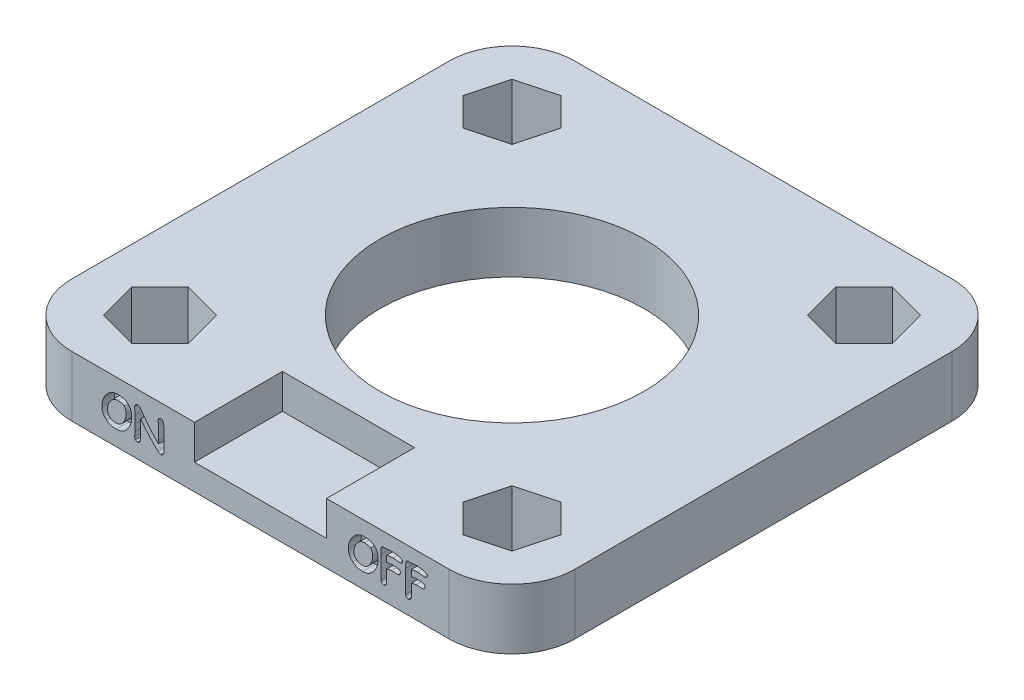
from build123d import *

# Parameters (mm, degrees)
SKICA1_W                 = 40
SKICA1_H                 = 40
SKICA1_R                 = 10.5
P_IDAT_VYSUNUT_M1_DEPTH  = 4.8
ZAOBLIT1_R               = 5
SKICA2_W                 = 10.5
SKICA2_H                 = 5.5
ODEBRAT_VYSUNUT_M1_DEPTH = 7
ODEBRAT_VYSUNUT_M2_DEPTH = 1


with BuildPart() as part:
    # Skica1 → Přidat vysunutím1 (new body)
    with BuildSketch(Plane(origin=(0, 0, 0), x_dir=(1, 0, 0), z_dir=(0, 1, 0))):
        Rectangle(SKICA1_W, SKICA1_H)
        Circle(SKICA1_R, mode=Mode.SUBTRACT)
        Polygon((-11.754634402, 11.754634402), (-10.932773553, 14.821860849), (-13.178139151, 17.067226447), (-16.245365598, 16.245365598), (-17.067226447, 13.178139151), (-14.821860849, 10.932773553), align=None, mode=Mode.SUBTRACT)
        Polygon((16.245365598, 16.245365598), (13.178139151, 17.067226447), (10.932773553, 14.821860849), (11.754634402, 11.754634402), (14.821860849, 10.932773553), (17.067226447, 13.178139151), align=None, mode=Mode.SUBTRACT)
        Polygon((16.245365598, -16.245365598), (17.067226447, -13.178139151), (14.821860849, -10.932773553), (11.754634402, -11.754634402), (10.932773553, -14.821860849), (13.178139151, -17.067226447), align=None, mode=Mode.SUBTRACT)
        Polygon((-16.245365598, -16.245365598), (-13.178139151, -17.067226447), (-10.932773553, -14.821860849), (-11.754634402, -11.754634402), (-14.821860849, -10.932773553), (-17.067226447, -13.178139151), align=None, mode=Mode.SUBTRACT)
    extrude(amount=P_IDAT_VYSUNUT_M1_DEPTH)

    # Zaoblit1
    zaoblit1_edges = [part.edges().sort_by_distance(p)[0] for p in [
        (-20, 2.4, -20),
        (20, 2.4, -20),
        (20, 2.4, 20),
        (-20, 2.4, 20),
    ]]
    fillet(zaoblit1_edges, radius=ZAOBLIT1_R)

    # Skica2 → Odebrat vysunutím1 (cut)
    with BuildSketch(Plane.XY.offset(20)):
        with Locations((0, 4.8)):
            Rectangle(SKICA2_W, SKICA2_H)
    extrude(amount=-ODEBRAT_VYSUNUT_M1_DEPTH, mode=Mode.SUBTRACT)

    # Skica4 → Odebrat vysunutím2 (cut)
    with BuildSketch(Plane.XY.offset(20)):
        with BuildLine():
            add(Edge.make_bspline(
                [(-7.675, 1.6875), (-7.675511427, 1.672680165), (-7.676669101, 1.639133729), (-7.681326512, 1.583160449), (-7.690705921, 1.516129992), (-7.697949225, 1.467739192), (-7.701851852, 1.441666667)],
                knots=[0, 0, 0, 0, 4.4483e-05, 0.000100693, 0.000168396, 0.000247488, 0.000247488, 0.000247488, 0.000247488], degree=3))
            add(Edge.make_bspline(
                [(-7.701851852, 1.441666667), (-7.704730232, 1.425795592), (-7.710210981, 1.395575329), (-7.726150475, 1.354217439), (-7.747242624, 1.319326551), (-7.773168281, 1.289940389), (-7.805193965, 1.267699725), (-7.842156121, 1.251696892), (-7.884276351, 1.242463261), (-7.913995971, 1.241334508), (-7.92962963, 1.240740741)],
                knots=[0, 0, 0, 0, 4.8308e-05, 9.1984e-05, 0.00013208, 0.000170105, 0.00020864, 0.000248033, 0.000290264, 0.000337135, 0.000337135, 0.000337135, 0.000337135], degree=3))
            add(Edge.make_bspline(
                [(-7.92962963, 1.240740741), (-7.938920109, 1.241081214), (-7.957997788, 1.241780364), (-7.986728041, 1.248240416), (-8.016262223, 1.258205907), (-8.046693038, 1.271577755), (-8.078048841, 1.289073024), (-8.110195974, 1.310312478), (-8.143340092, 1.335475378), (-8.164785779, 1.354479828), (-8.175925926, 1.364351852)],
                knots=[0, 0, 0, 0, 2.7839e-05, 5.7167e-05, 8.7912e-05, 0.000121287, 0.000156721, 0.000195499, 0.000236797, 0.000281438, 0.000281438, 0.000281438, 0.000281438], degree=3))
            add(Edge.make_bspline(
                [(-8.175925926, 1.364351852), (-8.201308744, 1.3874192), (-8.252786123, 1.434200714), (-8.329763202, 1.506939901), (-8.407365743, 1.583681364), (-8.487167676, 1.662997238), (-8.567559016, 1.746360031), (-8.648982608, 1.833282723), (-8.732566347, 1.922608612), (-8.816068769, 2.01666789), (-8.901836173, 2.113052363), (-8.988450373, 2.213317447), (-9.076331212, 2.316814446), (-9.165139145, 2.423960411), (-9.255637306, 2.534001749), (-9.346594942, 2.64806528), (-9.439421484, 2.765168862), (-9.501155437, 2.844848471), (-9.532407407, 2.885185185)],
                knots=[0, 0, 0, 0, 0.000102894, 0.000208674, 0.000317691, 0.000430304, 0.000546208, 0.000665096, 0.000787616, 0.000913184, 0.001042405, 0.001174674, 0.001310659, 0.001449721, 0.001592167, 0.001738074, 0.001887382, 0.002040461, 0.002040461, 0.002040461, 0.002040461], degree=3))
            add(Edge.make_bspline(
                [(-9.532407407, 2.885185185), (-9.533211671, 2.852932842), (-9.534739345, 2.791670556), (-9.536404499, 2.704780063), (-9.538402842, 2.627780862), (-9.53984509, 2.560651506), (-9.540602809, 2.503238161), (-9.54166635, 2.455558488), (-9.542202023, 2.417748159), (-9.542151132, 2.395833424), (-9.54212963, 2.386574074)],
                knots=[0, 0, 0, 0, 9.6787e-05, 0.000183844, 0.000260718, 0.000327862, 0.000385277, 0.000432971, 0.000470937, 0.000498714, 0.000498714, 0.000498714, 0.000498714], degree=3))
            add(Edge.make_bspline(
                [(-9.54212963, 2.386574074), (-9.542178103, 2.375616956), (-9.542280516, 2.35246714), (-9.541413081, 2.315743629), (-9.542008358, 2.275147603), (-9.540440371, 2.230561865), (-9.540459618, 2.182094232), (-9.539261113, 2.129630937), (-9.53837092, 2.073303523), (-9.537668837, 2.014345624), (-9.53597861, 1.955561133), (-9.535296212, 1.899380869), (-9.534140414, 1.847071663), (-9.533853328, 1.798610433), (-9.533331962, 1.754012331), (-9.532940471, 1.713425303), (-9.532295161, 1.676699235), (-9.532371347, 1.653549616), (-9.532407407, 1.642592593)],
                knots=[0, 0, 0, 0, 3.287e-05, 6.9447e-05, 0.000110188, 0.000154642, 0.000203256, 0.000255579, 0.000312068, 0.00037226, 0.000432461, 0.000488487, 0.00054081, 0.000589424, 0.00063387, 0.000674614, 0.000711191, 0.000744061, 0.000744061, 0.000744061, 0.000744061], degree=3))
            add(Edge.make_bspline(
                [(-9.532407407, 1.642592593), (-9.532551422, 1.623914249), (-9.532828913, 1.587924434), (-9.535894121, 1.535757937), (-9.539611953, 1.487029933), (-9.546283713, 1.441971649), (-9.554003323, 1.400346416), (-9.563614635, 1.36240846), (-9.575133233, 1.328014341), (-9.588429995, 1.297215657), (-9.603955118, 1.270280491), (-9.620375128, 1.246152691), (-9.639548216, 1.22631449), (-9.660087891, 1.209699676), (-9.682615625, 1.196984891), (-9.706937261, 1.188381823), (-9.732892375, 1.182390183), (-9.750889754, 1.181790968), (-9.760185185, 1.181481481)],
                knots=[0, 0, 0, 0, 5.6026e-05, 0.000107952, 0.000156742, 0.000202573, 0.000244521, 0.000283709, 0.000319871, 0.000353246, 0.00038414, 0.000413041, 0.000440547, 0.000466576, 0.000492073, 0.000517704, 0.000543766, 0.000571605, 0.000571605, 0.000571605, 0.000571605], degree=3))
            add(Edge.make_bspline(
                [(-9.760185185, 1.181481481), (-9.77848016, 1.182370462), (-9.813712587, 1.184082458), (-9.86386568, 1.197234545), (-9.908537754, 1.219441479), (-9.932825116, 1.241084865), (-9.944907407, 1.251851852)],
                knots=[0, 0, 0, 0, 5.4825e-05, 0.000105583, 0.000154447, 0.000202819, 0.000202819, 0.000202819, 0.000202819], degree=3))
            add(Edge.make_bspline(
                [(-9.944907407, 1.251851852), (-9.95431763, 1.262472954), (-9.972820924, 1.283357195), (-9.992537503, 1.32044514), (-10.004548777, 1.360828141), (-10.005830699, 1.388959533), (-10.006481481, 1.403240741)],
                knots=[0, 0, 0, 0, 4.2444e-05, 8.3457e-05, 0.00012492, 0.000167674, 0.000167674, 0.000167674, 0.000167674], degree=3))
            add(Edge.make_bspline(
                [(-10.006481481, 1.403240741), (-10.006408492, 1.415125665), (-10.006247274, 1.441377168), (-10.004012298, 1.484731606), (-10.001453692, 1.535988986), (-9.997221437, 1.59259256), (-9.992993684, 1.649196322), (-9.990416232, 1.700607223), (-9.988212611, 1.743962883), (-9.988040066, 1.770213972), (-9.987962963, 1.781944444)],
                knots=[0, 0, 0, 0, 3.5651e-05, 7.8747e-05, 0.00013021, 0.000189616, 0.000249022, 0.000300485, 0.000344043, 0.000379232, 0.000379232, 0.000379232, 0.000379232], degree=3))
            add(Edge.make_bspline(
                [(-9.987962963, 1.781944444), (-9.98782225, 1.799228478), (-9.987509403, 1.837655999), (-9.986661924, 1.900933966), (-9.984600036, 1.97577271), (-9.982408805, 2.058333368), (-9.980205469, 2.141048046), (-9.978158964, 2.216041497), (-9.977304677, 2.279473613), (-9.976992337, 2.317901146), (-9.976851852, 2.335185185)],
                knots=[0, 0, 0, 0, 5.1854e-05, 0.000115287, 0.000189847, 0.000276452, 0.000363057, 0.00043808, 0.000501512, 0.000553366, 0.000553366, 0.000553366, 0.000553366], degree=3))
            add(Edge.make_bspline(
                [(-9.976851852, 2.335185185), (-9.97678822, 2.353704155), (-9.976646633, 2.394910961), (-9.977970855, 2.462806695), (-9.978652907, 2.543212466), (-9.980034143, 2.63194495), (-9.981752747, 2.720827498), (-9.981605453, 2.801393435), (-9.983101732, 2.869440664), (-9.982942108, 2.910647627), (-9.98287037, 2.929166667)],
                knots=[0, 0, 0, 0, 5.5556e-05, 0.000123617, 0.000203715, 0.000296781, 0.000389847, 0.000470404, 0.000538466, 0.000594021, 0.000594021, 0.000594021, 0.000594021], degree=3))
            add(Edge.make_bspline(
                [(-9.98287037, 2.929166667), (-9.983158143, 2.946759248), (-9.983796888, 2.985808011), (-9.985355078, 3.050045791), (-9.990133751, 3.125618751), (-9.994868779, 3.208952511), (-9.999876142, 3.292264377), (-10.003856848, 3.368025092), (-10.005580831, 3.432246198), (-10.006201743, 3.471295889), (-10.006481481, 3.488888889)],
                knots=[0, 0, 0, 0, 5.2786e-05, 0.000117164, 0.000192742, 0.000279928, 0.000367576, 0.00044313, 0.000507509, 0.000560294, 0.000560294, 0.000560294, 0.000560294], degree=3))
            add(Edge.make_bspline(
                [(-10.006481481, 3.488888889), (-10.005498041, 3.504293031), (-10.003543578, 3.534906799), (-9.987767889, 3.579006901), (-9.962498502, 3.620217196), (-9.927903294, 3.657124199), (-9.887891573, 3.689377385), (-9.842904366, 3.712304065), (-9.795369388, 3.727098946), (-9.762453869, 3.728780525), (-9.745833333, 3.72962963)],
                knots=[0, 0, 0, 0, 4.6115e-05, 9.1648e-05, 0.000138812, 0.000190259, 0.00024268, 0.000292167, 0.000340946, 0.000390699, 0.000390699, 0.000390699, 0.000390699], degree=3))
            add(Edge.make_bspline(
                [(-9.745833333, 3.72962963), (-9.736044085, 3.728939831), (-9.715899661, 3.727520354), (-9.685625695, 3.717509608), (-9.655061251, 3.701465563), (-9.623732637, 3.679242201), (-9.591958306, 3.650671327), (-9.558993507, 3.616170295), (-9.525299697, 3.575456888), (-9.50381988, 3.54536064), (-9.492592593, 3.52962963)],
                knots=[0, 0, 0, 0, 2.9346e-05, 6.0389e-05, 9.4761e-05, 0.00013265, 0.000175288, 0.000222766, 0.0002757, 0.000333666, 0.000333666, 0.000333666, 0.000333666], degree=3))
            add(Edge.make_bspline(
                [(-9.492592593, 3.52962963), (-9.434624361, 3.446806863), (-9.320656625, 3.28397417), (-9.146260709, 3.048194745), (-8.972750905, 2.823946105), (-8.799617494, 2.611320211), (-8.627126941, 2.410381302), (-8.455159881, 2.221255869), (-8.284216532, 2.043398787), (-8.167511555, 1.931712837), (-8.110185185, 1.876851852)],
                knots=[0, 0, 0, 0, 0.00030327, 0.000596241, 0.000879702, 0.001153812, 0.001418749, 0.001674053, 0.001920595, 0.002158616, 0.002158616, 0.002158616, 0.002158616], degree=3))
            add(Edge.make_bspline(
                [(-8.110185185, 1.876851852), (-8.109988216, 1.881635158), (-8.109530875, 1.892741484), (-8.109924711, 1.911578007), (-8.109000506, 1.93471804), (-8.109479001, 1.962040033), (-8.108571636, 1.993669972), (-8.108867579, 2.029630179), (-8.108775419, 2.069907246), (-8.108789113, 2.098148093), (-8.108796296, 2.112962963)],
                knots=[0, 0, 0, 0, 1.4359e-05, 3.3341e-05, 5.6494e-05, 8.3808e-05, 0.000115293, 0.000151404, 0.000191682, 0.000236127, 0.000236127, 0.000236127, 0.000236127], degree=3))
            add(Edge.make_bspline(
                [(-8.108796296, 2.112962963), (-8.108813437, 2.144290077), (-8.108846958, 2.205555418), (-8.108607371, 2.295525618), (-8.109459456, 2.381480515), (-8.109078935, 2.463581233), (-8.109758042, 2.541820882), (-8.110144507, 2.616204006), (-8.110695584, 2.686727832), (-8.110900117, 2.753244749), (-8.112222161, 2.815891192), (-8.112306081, 2.874695585), (-8.11342801, 2.929629834), (-8.114305612, 2.98055631), (-8.115235434, 3.027624511), (-8.116201545, 3.070832899), (-8.116932334, 3.110196304), (-8.118009777, 3.13503232), (-8.118518519, 3.146759259)],
                knots=[0, 0, 0, 0, 9.3981e-05, 0.000183796, 0.000269909, 0.000351853, 0.000430095, 0.000504634, 0.000575006, 0.000641674, 0.000704181, 0.000762979, 0.000818079, 0.000869014, 0.000915782, 0.00095931, 0.000998673, 0.001033886, 0.001033886, 0.001033886, 0.001033886], degree=3))
            add(Edge.make_bspline(
                [(-8.118518519, 3.146759259), (-8.118965229, 3.155865011), (-8.120018046, 3.177325674), (-8.122304892, 3.214379381), (-8.126210891, 3.261113401), (-8.129019082, 3.295524283), (-8.130555556, 3.314351852)],
                knots=[0, 0, 0, 0, 2.735e-05, 6.4459e-05, 0.000111365, 0.000168036, 0.000168036, 0.000168036, 0.000168036], degree=3))
            add(Edge.make_bspline(
                [(-8.130555556, 3.314351852), (-8.132036264, 3.331475143), (-8.134835699, 3.363848536), (-8.137392637, 3.409555281), (-8.139600915, 3.449515973), (-8.139747196, 3.474225888), (-8.139814815, 3.485648148)],
                knots=[0, 0, 0, 0, 5.1558e-05, 9.7475e-05, 0.000137333, 0.000171595, 0.000171595, 0.000171595, 0.000171595], degree=3))
            add(Edge.make_bspline(
                [(-8.139814815, 3.485648148), (-8.139107689, 3.502521065), (-8.13777595, 3.534298058), (-8.127874444, 3.578820932), (-8.1100512, 3.61672737), (-8.084303566, 3.64742075), (-8.051867275, 3.671961514), (-8.011836365, 3.688237651), (-7.965341287, 3.698597999), (-7.932007884, 3.699514531), (-7.914351852, 3.7)],
                knots=[0, 0, 0, 0, 5.0599e-05, 9.5293e-05, 0.000135878, 0.000175001, 0.000214353, 0.000256663, 0.000303614, 0.000356491, 0.000356491, 0.000356491, 0.000356491], degree=3))
            add(Edge.make_bspline(
                [(-7.914351852, 3.7), (-7.904109101, 3.69931314), (-7.883858826, 3.697955195), (-7.854457832, 3.688987364), (-7.827416078, 3.673108337), (-7.802955346, 3.650814869), (-7.779918411, 3.623008698), (-7.759259386, 3.588946763), (-7.74092618, 3.548735918), (-7.724361835, 3.502711815), (-7.709643732, 3.450562123), (-7.696798423, 3.392448054), (-7.68631421, 3.328123521), (-7.67762089, 3.25784816), (-7.670773441, 3.181259005), (-7.665663258, 3.098671741), (-7.66301741, 3.009894256), (-7.662676462, 2.948766993), (-7.6625, 2.91712963)],
                knots=[0, 0, 0, 0, 3.0727e-05, 6.0748e-05, 9.1241e-05, 0.000124036, 0.000159542, 0.000199244, 0.000243155, 0.000291924, 0.000345851, 0.000405607, 0.000470378, 0.000541296, 0.000618, 0.000701026, 0.000789496, 0.000884408, 0.000884408, 0.000884408, 0.000884408], degree=3))
            add(Edge.make_bspline(
                [(-7.6625, 2.91712963), (-7.662502308, 2.91466052), (-7.662509087, 2.907407512), (-7.662405402, 2.893207072), (-7.663094897, 2.872378661), (-7.663451442, 2.844907821), (-7.663932278, 2.810803008), (-7.664405643, 2.770062341), (-7.664738916, 2.722836409), (-7.665392791, 2.689197005), (-7.665740741, 2.671296296)],
                knots=[0, 0, 0, 0, 7.407e-06, 2.1759e-05, 4.2598e-05, 6.9916e-05, 0.000104179, 0.000144922, 0.000192147, 0.000245858, 0.000245858, 0.000245858, 0.000245858], degree=3))
            add(Edge.make_bspline(
                [(-7.665740741, 2.671296296), (-7.665990759, 2.639196801), (-7.666479993, 2.576384661), (-7.668179686, 2.484571473), (-7.668934688, 2.397375947), (-7.669833129, 2.3149684), (-7.670997312, 2.237194309), (-7.671067907, 2.16403942), (-7.672368996, 2.095527788), (-7.672630296, 2.031635286), (-7.673133211, 1.972376455), (-7.673605286, 1.917901118), (-7.673990872, 1.868055), (-7.674718292, 1.822995629), (-7.674316364, 1.782405037), (-7.675147453, 1.746606865), (-7.674971466, 1.715431917), (-7.674991014, 1.696296239), (-7.675, 1.6875)],
                knots=[0, 0, 0, 0, 9.6301e-05, 0.000188441, 0.000275483, 0.000357895, 0.000435679, 0.000508828, 0.000577353, 0.000641244, 0.000700505, 0.000755136, 0.000804676, 0.000850048, 0.000890326, 0.00092644, 0.000957459, 0.000983848, 0.000983848, 0.000983848, 0.000983848], degree=3))
        make_face()
        with BuildLine():
            add(Edge.make_bspline(
                [(-11.475925926, 1.211111111), (-11.513924551, 1.211878388), (-11.588590406, 1.213386058), (-11.698518349, 1.22627778), (-11.803949591, 1.246954828), (-11.905396947, 1.275662725), (-12.002111211, 1.313342182), (-12.094929428, 1.358850221), (-12.183252906, 1.413061288), (-12.238160298, 1.455214818), (-12.265740741, 1.476388889)],
                knots=[0, 0, 0, 0, 0.000113965, 0.000223937, 0.000331529, 0.000436012, 0.000539784, 0.000642479, 0.000745782, 0.000850043, 0.000850043, 0.000850043, 0.000850043], degree=3))
            add(Edge.make_bspline(
                [(-12.265740741, 1.476388889), (-12.293439014, 1.500358502), (-12.347845978, 1.547441362), (-12.419098636, 1.626781287), (-12.479160157, 1.711558542), (-12.528740928, 1.801363321), (-12.566795992, 1.89660731), (-12.594281845, 1.996880477), (-12.61071178, 2.102544857), (-12.612816927, 2.174787449), (-12.613888889, 2.211574074)],
                knots=[0, 0, 0, 0, 0.000109808, 0.000215693, 0.000318971, 0.000420912, 0.000522701, 0.000625918, 0.000732252, 0.000842578, 0.000842578, 0.000842578, 0.000842578], degree=3))
            add(Edge.make_bspline(
                [(-12.613888889, 2.211574074), (-12.612971602, 2.255297134), (-12.61115042, 2.342104908), (-12.594665415, 2.470747926), (-12.569053938, 2.596584431), (-12.532191464, 2.719397676), (-12.484708639, 2.839159434), (-12.427069417, 2.955994396), (-12.35950786, 3.07024689), (-12.306792735, 3.142239527), (-12.280092593, 3.178703704)],
                knots=[0, 0, 0, 0, 0.000131117, 0.000260321, 0.000388434, 0.000516011, 0.000644452, 0.000774478, 0.000906516, 0.001042032, 0.001042032, 0.001042032, 0.001042032], degree=3))
            add(Edge.make_bspline(
                [(-12.280092593, 3.178703704), (-12.264410075, 3.198786289), (-12.233516561, 3.238347644), (-12.184112043, 3.293902585), (-12.133648966, 3.346026406), (-12.081434838, 3.394141669), (-12.027523057, 3.438189993), (-11.972328611, 3.478737274), (-11.915327301, 3.515195551), (-11.857053538, 3.548283709), (-11.797065453, 3.576878562), (-11.735860089, 3.602250036), (-11.672688987, 3.622701493), (-11.608399939, 3.640606313), (-11.542494622, 3.654051999), (-11.475026704, 3.662978555), (-11.406144614, 3.669488089), (-11.359583564, 3.670074665), (-11.336111111, 3.67037037)],
                knots=[0, 0, 0, 0, 7.6424e-05, 0.00015055, 0.000222904, 0.000294003, 0.000363418, 0.000431664, 0.000499342, 0.000566299, 0.000632561, 0.000698588, 0.000764909, 0.000831622, 0.00089872, 0.000966485, 0.001035728, 0.001106123, 0.001106123, 0.001106123, 0.001106123], degree=3))
            add(Edge.make_bspline(
                [(-11.336111111, 3.67037037), (-11.291943277, 3.669794678), (-11.206209347, 3.668677206), (-11.082020358, 3.656217695), (-10.966162804, 3.637217959), (-10.858883204, 3.610054371), (-10.760114932, 3.575036708), (-10.670201899, 3.531701705), (-10.588256903, 3.481204395), (-10.515284525, 3.42209487), (-10.450755036, 3.355252361), (-10.394602907, 3.280630938), (-10.348038433, 3.197549585), (-10.309275319, 3.107148036), (-10.279885672, 3.008752494), (-10.25885365, 2.902734973), (-10.245589224, 2.788915656), (-10.244222685, 2.710377501), (-10.243518519, 2.669907407)],
                knots=[0, 0, 0, 0, 0.000132459, 0.000257116, 0.000374022, 0.0004844, 0.000588664, 0.000687848, 0.000783297, 0.000876786, 0.00096879, 0.001061382, 0.001156132, 0.001253821, 0.001355901, 0.001463584, 0.001577748, 0.001699116, 0.001699116, 0.001699116, 0.001699116], degree=3))
            add(Edge.make_bspline(
                [(-10.243518519, 2.669907407), (-10.244352765, 2.626193859), (-10.246005229, 2.539606701), (-10.260903308, 2.411288165), (-10.284772295, 2.28601213), (-10.31885002, 2.163959459), (-10.36185509, 2.044936317), (-10.415131147, 1.929313931), (-10.477313805, 1.816285261), (-10.526245557, 1.744834754), (-10.550925926, 1.708796296)],
                knots=[0, 0, 0, 0, 0.0001311, 0.000259682, 0.000386979, 0.000513341, 0.000639438, 0.000766223, 0.000894919, 0.00102589, 0.00102589, 0.00102589, 0.00102589], degree=3))
            add(Edge.make_bspline(
                [(-10.550925926, 1.708796296), (-10.565649186, 1.688542987), (-10.594807189, 1.648433253), (-10.642181498, 1.59247918), (-10.690368163, 1.539481513), (-10.740966842, 1.491166506), (-10.79268027, 1.44589285), (-10.846630931, 1.405313717), (-10.901694131, 1.367931773), (-10.95891015, 1.335066247), (-11.017710912, 1.305968515), (-11.078018129, 1.280210784), (-11.140312165, 1.259063361), (-11.20410534, 1.241344467), (-11.269727632, 1.227991526), (-11.336967352, 1.21834675), (-11.405897938, 1.212034058), (-11.452455322, 1.211420446), (-11.475925926, 1.211111111)],
                knots=[0, 0, 0, 0, 7.5093e-05, 0.000148714, 0.000219813, 0.000289881, 0.000358477, 0.000425885, 0.00049227, 0.00055802, 0.000623653, 0.000689003, 0.000754594, 0.000820861, 0.000887505, 0.000955335, 0.001024578, 0.001094973, 0.001094973, 0.001094973, 0.001094973], degree=3))
        make_face()
        with BuildLine():
            add(Edge.make_bspline(
                [(-11.336111111, 3.255555556), (-11.364902017, 3.254704064), (-11.421724115, 3.25302355), (-11.505023923, 3.235757178), (-11.585508715, 3.209548111), (-11.662519813, 3.171587771), (-11.736370673, 3.123245603), (-11.807060112, 3.064436951), (-11.874363135, 2.99469228), (-11.914845899, 2.942233801), (-11.935648148, 2.915277778)],
                knots=[0, 0, 0, 0, 8.6262e-05, 0.000170247, 0.000254135, 0.000339648, 0.000426967, 0.000518371, 0.000614957, 0.000717049, 0.000717049, 0.000717049, 0.000717049], degree=3))
            add(Edge.make_bspline(
                [(-11.935648148, 2.915277778), (-11.954274394, 2.88869707), (-11.99119738, 2.836005877), (-12.038846865, 2.752824455), (-12.079243094, 2.667527112), (-12.112325969, 2.580080784), (-12.137932771, 2.490416051), (-12.155704589, 2.398540239), (-12.167404983, 2.304621639), (-12.168760515, 2.241238854), (-12.169444444, 2.209259259)],
                knots=[0, 0, 0, 0, 9.7332e-05, 0.000192943, 0.00028717, 0.000380208, 0.000473117, 0.000566545, 0.000660721, 0.000756626, 0.000756626, 0.000756626, 0.000756626], degree=3))
            add(Edge.make_bspline(
                [(-12.169444444, 2.209259259), (-12.168801209, 2.187930374), (-12.167536481, 2.145993592), (-12.158183712, 2.084619134), (-12.14247421, 2.02631615), (-12.120007889, 1.971156115), (-12.091139628, 1.919174874), (-12.056164434, 1.870151279), (-12.014655551, 1.824482189), (-11.983165348, 1.797217367), (-11.96712963, 1.783333333)],
                knots=[0, 0, 0, 0, 6.3971e-05, 0.00012578, 0.000185753, 0.000244729, 0.000303995, 0.000363734, 0.000425022, 0.000488615, 0.000488615, 0.000488615, 0.000488615], degree=3))
            add(Edge.make_bspline(
                [(-11.96712963, 1.783333333), (-11.950536892, 1.770662495), (-11.91748584, 1.745423468), (-11.863657419, 1.713264999), (-11.806561864, 1.686656485), (-11.746597747, 1.664115195), (-11.68328242, 1.647185942), (-11.617071378, 1.634672271), (-11.547554424, 1.627070689), (-11.500173755, 1.626313453), (-11.475925926, 1.625925926)],
                knots=[0, 0, 0, 0, 6.2596e-05, 0.000124685, 0.000187643, 0.000251365, 0.000316617, 0.00038399, 0.000453368, 0.00052609, 0.00052609, 0.00052609, 0.00052609], degree=3))
            add(Edge.make_bspline(
                [(-11.475925926, 1.625925926), (-11.44759706, 1.626781161), (-11.391691028, 1.628468938), (-11.310049618, 1.645620862), (-11.231763737, 1.671755074), (-11.157727945, 1.710130031), (-11.086811029, 1.758056011), (-11.019795786, 1.817117535), (-10.956629111, 1.886856818), (-10.919233004, 1.939255038), (-10.9, 1.966203704)],
                knots=[0, 0, 0, 0, 8.4875e-05, 0.000167498, 0.000249192, 0.000331805, 0.00041681, 0.000505395, 0.000599133, 0.000698393, 0.000698393, 0.000698393, 0.000698393], degree=3))
            add(Edge.make_bspline(
                [(-10.9, 1.966203704), (-10.883078673, 1.992347779), (-10.849458932, 2.044291519), (-10.806436696, 2.126284588), (-10.769703294, 2.21075275), (-10.739566138, 2.297861255), (-10.716204817, 2.387634709), (-10.700436119, 2.480128647), (-10.689600558, 2.575206643), (-10.688513118, 2.639629532), (-10.687962963, 2.672222222)],
                knots=[0, 0, 0, 0, 9.3388e-05, 0.000185545, 0.0002774, 0.000369492, 0.000461794, 0.000555338, 0.00065079, 0.000748529, 0.000748529, 0.000748529, 0.000748529], degree=3))
            add(Edge.make_bspline(
                [(-10.687962963, 2.672222222), (-10.688367495, 2.698781978), (-10.689145146, 2.749839002), (-10.696148345, 2.82334226), (-10.707464285, 2.890582184), (-10.723446891, 2.951617201), (-10.744439327, 3.006181566), (-10.769198783, 3.054927664), (-10.799416894, 3.097388386), (-10.823701782, 3.120860745), (-10.835648148, 3.132407407)],
                knots=[0, 0, 0, 0, 7.9663e-05, 0.00015314, 0.00022126, 0.000284036, 0.000342071, 0.000396322, 0.00044772, 0.000497483, 0.000497483, 0.000497483, 0.000497483], degree=3))
            add(Edge.make_bspline(
                [(-10.835648148, 3.132407407), (-10.848360505, 3.14234639), (-10.874697186, 3.162937365), (-10.920936411, 3.187669578), (-10.973578727, 3.208907132), (-11.032973463, 3.226321078), (-11.09911277, 3.23968506), (-11.172042181, 3.248398265), (-11.251739735, 3.254788404), (-11.307238543, 3.25529303), (-11.336111111, 3.255555556)],
                knots=[0, 0, 0, 0, 4.8335e-05, 0.000100137, 0.00015662, 0.000218436, 0.000285534, 0.000358806, 0.000438663, 0.000525257, 0.000525257, 0.000525257, 0.000525257], degree=3))
        make_face(mode=Mode.SUBTRACT)
        with BuildLine():
            add(Edge.make_bspline(
                [(8.122222222, 1.211111111), (8.084223597, 1.211878388), (8.009557742, 1.213386058), (7.899629799, 1.22627778), (7.794198557, 1.246954828), (7.692751201, 1.275662725), (7.596036937, 1.313342182), (7.50321872, 1.358850221), (7.414895242, 1.413061288), (7.35998785, 1.455214818), (7.332407407, 1.476388889)],
                knots=[0, 0, 0, 0, 0.000113965, 0.000223937, 0.000331529, 0.000436012, 0.000539784, 0.000642479, 0.000745782, 0.000850043, 0.000850043, 0.000850043, 0.000850043], degree=3))
            add(Edge.make_bspline(
                [(7.332407407, 1.476388889), (7.304709135, 1.500358502), (7.25030217, 1.547441362), (7.179049512, 1.626781287), (7.118987991, 1.711558542), (7.06940722, 1.801363321), (7.031352156, 1.89660731), (7.003866303, 1.996880477), (6.987436369, 2.102544857), (6.985331221, 2.174787449), (6.984259259, 2.211574074)],
                knots=[0, 0, 0, 0, 0.000109808, 0.000215693, 0.000318971, 0.000420912, 0.000522701, 0.000625918, 0.000732252, 0.000842578, 0.000842578, 0.000842578, 0.000842578], degree=3))
            add(Edge.make_bspline(
                [(6.984259259, 2.211574074), (6.985176546, 2.255297134), (6.986997728, 2.342104908), (7.003482733, 2.470747926), (7.02909421, 2.596584431), (7.065956684, 2.719397676), (7.113439509, 2.839159434), (7.171078731, 2.955994396), (7.238640289, 3.07024689), (7.291355413, 3.142239527), (7.318055556, 3.178703704)],
                knots=[0, 0, 0, 0, 0.000131117, 0.000260321, 0.000388434, 0.000516011, 0.000644452, 0.000774478, 0.000906516, 0.001042032, 0.001042032, 0.001042032, 0.001042032], degree=3))
            add(Edge.make_bspline(
                [(7.318055556, 3.178703704), (7.333738073, 3.198786289), (7.364631587, 3.238347644), (7.414036105, 3.293902585), (7.464499183, 3.346026406), (7.51671331, 3.394141669), (7.570625091, 3.438189993), (7.625819537, 3.478737274), (7.682820847, 3.515195551), (7.74109461, 3.548283709), (7.801082695, 3.576878562), (7.862288059, 3.602250036), (7.925459161, 3.622701493), (7.98974821, 3.640606313), (8.055653526, 3.654051999), (8.123121444, 3.662978555), (8.192003534, 3.669488089), (8.238564584, 3.670074665), (8.262037037, 3.67037037)],
                knots=[0, 0, 0, 0, 7.6424e-05, 0.00015055, 0.000222904, 0.000294003, 0.000363418, 0.000431664, 0.000499342, 0.000566299, 0.000632561, 0.000698588, 0.000764909, 0.000831622, 0.00089872, 0.000966485, 0.001035728, 0.001106123, 0.001106123, 0.001106123, 0.001106123], degree=3))
            add(Edge.make_bspline(
                [(8.262037037, 3.67037037), (8.306204871, 3.669794678), (8.391938801, 3.668677206), (8.51612779, 3.656217695), (8.631985344, 3.637217959), (8.739264945, 3.610054371), (8.838033217, 3.575036708), (8.927946249, 3.531701705), (9.009891245, 3.481204395), (9.082863623, 3.42209487), (9.147393112, 3.355252361), (9.203545242, 3.280630938), (9.250109715, 3.197549585), (9.288872829, 3.107148036), (9.318262476, 3.008752494), (9.339294498, 2.902734973), (9.352558924, 2.788915656), (9.353925463, 2.710377501), (9.35462963, 2.669907407)],
                knots=[0, 0, 0, 0, 0.000132459, 0.000257116, 0.000374022, 0.0004844, 0.000588664, 0.000687848, 0.000783297, 0.000876786, 0.00096879, 0.001061382, 0.001156132, 0.001253821, 0.001355901, 0.001463584, 0.001577748, 0.001699116, 0.001699116, 0.001699116, 0.001699116], degree=3))
            add(Edge.make_bspline(
                [(9.35462963, 2.669907407), (9.353795383, 2.626193859), (9.352142919, 2.539606701), (9.33724484, 2.411288165), (9.313375853, 2.28601213), (9.279298128, 2.163959459), (9.236293058, 2.044936317), (9.183017001, 1.929313931), (9.120834343, 1.816285261), (9.071902591, 1.744834754), (9.047222222, 1.708796296)],
                knots=[0, 0, 0, 0, 0.0001311, 0.000259682, 0.000386979, 0.000513341, 0.000639438, 0.000766223, 0.000894919, 0.00102589, 0.00102589, 0.00102589, 0.00102589], degree=3))
            add(Edge.make_bspline(
                [(9.047222222, 1.708796296), (9.032498962, 1.688542987), (9.003340959, 1.648433253), (8.95596665, 1.59247918), (8.907779985, 1.539481513), (8.857181306, 1.491166506), (8.805467878, 1.44589285), (8.751517217, 1.405313717), (8.696454017, 1.367931773), (8.639237998, 1.335066247), (8.580437236, 1.305968515), (8.52013002, 1.280210784), (8.457835983, 1.259063361), (8.394042808, 1.241344467), (8.328420516, 1.227991526), (8.261180796, 1.21834675), (8.19225021, 1.212034058), (8.145692827, 1.211420446), (8.122222222, 1.211111111)],
                knots=[0, 0, 0, 0, 7.5093e-05, 0.000148714, 0.000219813, 0.000289881, 0.000358477, 0.000425885, 0.00049227, 0.00055802, 0.000623653, 0.000689003, 0.000754594, 0.000820861, 0.000887505, 0.000955335, 0.001024578, 0.001094973, 0.001094973, 0.001094973, 0.001094973], degree=3))
        make_face()
        with BuildLine():
            add(Edge.make_bspline(
                [(8.262037037, 3.255555556), (8.233246131, 3.254704064), (8.176424033, 3.25302355), (8.093124225, 3.235757178), (8.012639433, 3.209548111), (7.935628335, 3.171587771), (7.861777476, 3.123245603), (7.791088037, 3.064436951), (7.723785013, 2.99469228), (7.683302249, 2.942233801), (7.6625, 2.915277778)],
                knots=[0, 0, 0, 0, 8.6262e-05, 0.000170247, 0.000254135, 0.000339648, 0.000426967, 0.000518371, 0.000614957, 0.000717049, 0.000717049, 0.000717049, 0.000717049], degree=3))
            add(Edge.make_bspline(
                [(7.6625, 2.915277778), (7.643873754, 2.88869707), (7.606950768, 2.836005877), (7.559301283, 2.752824455), (7.518905054, 2.667527112), (7.485822179, 2.580080784), (7.460215378, 2.490416051), (7.442443559, 2.398540239), (7.430743165, 2.304621639), (7.429387633, 2.241238854), (7.428703704, 2.209259259)],
                knots=[0, 0, 0, 0, 9.7332e-05, 0.000192943, 0.00028717, 0.000380208, 0.000473117, 0.000566545, 0.000660721, 0.000756626, 0.000756626, 0.000756626, 0.000756626], degree=3))
            add(Edge.make_bspline(
                [(7.428703704, 2.209259259), (7.429346939, 2.187930374), (7.430611667, 2.145993592), (7.439964436, 2.084619134), (7.455673938, 2.02631615), (7.478140259, 1.971156115), (7.507008521, 1.919174874), (7.541983714, 1.870151279), (7.583492597, 1.824482189), (7.6149828, 1.797217367), (7.631018519, 1.783333333)],
                knots=[0, 0, 0, 0, 6.3971e-05, 0.00012578, 0.000185753, 0.000244729, 0.000303995, 0.000363734, 0.000425022, 0.000488615, 0.000488615, 0.000488615, 0.000488615], degree=3))
            add(Edge.make_bspline(
                [(7.631018519, 1.783333333), (7.647611256, 1.770662495), (7.680662308, 1.745423468), (7.734490729, 1.713264999), (7.791586284, 1.686656485), (7.851550401, 1.664115195), (7.914865728, 1.647185942), (7.98107677, 1.634672271), (8.050593724, 1.627070689), (8.097974393, 1.626313453), (8.122222222, 1.625925926)],
                knots=[0, 0, 0, 0, 6.2596e-05, 0.000124685, 0.000187643, 0.000251365, 0.000316617, 0.00038399, 0.000453368, 0.00052609, 0.00052609, 0.00052609, 0.00052609], degree=3))
            add(Edge.make_bspline(
                [(8.122222222, 1.625925926), (8.150551088, 1.626781161), (8.20645712, 1.628468938), (8.28809853, 1.645620862), (8.366384411, 1.671755074), (8.440420203, 1.710130031), (8.51133712, 1.758056011), (8.578352362, 1.817117535), (8.641519038, 1.886856818), (8.678915145, 1.939255038), (8.698148148, 1.966203704)],
                knots=[0, 0, 0, 0, 8.4875e-05, 0.000167498, 0.000249192, 0.000331805, 0.00041681, 0.000505395, 0.000599133, 0.000698393, 0.000698393, 0.000698393, 0.000698393], degree=3))
            add(Edge.make_bspline(
                [(8.698148148, 1.966203704), (8.715069475, 1.992347779), (8.748689216, 2.044291519), (8.791711452, 2.126284588), (8.828444854, 2.21075275), (8.85858201, 2.297861255), (8.881943331, 2.387634709), (8.897712029, 2.480128647), (8.90854759, 2.575206643), (8.90963503, 2.639629532), (8.910185185, 2.672222222)],
                knots=[0, 0, 0, 0, 9.3388e-05, 0.000185545, 0.0002774, 0.000369492, 0.000461794, 0.000555338, 0.00065079, 0.000748529, 0.000748529, 0.000748529, 0.000748529], degree=3))
            add(Edge.make_bspline(
                [(8.910185185, 2.672222222), (8.909780653, 2.698781978), (8.909003002, 2.749839002), (8.901999803, 2.82334226), (8.890683864, 2.890582184), (8.874701257, 2.951617201), (8.853708821, 3.006181566), (8.828949365, 3.054927664), (8.798731254, 3.097388386), (8.774446366, 3.120860745), (8.7625, 3.132407407)],
                knots=[0, 0, 0, 0, 7.9663e-05, 0.00015314, 0.00022126, 0.000284036, 0.000342071, 0.000396322, 0.00044772, 0.000497483, 0.000497483, 0.000497483, 0.000497483], degree=3))
            add(Edge.make_bspline(
                [(8.7625, 3.132407407), (8.749787644, 3.14234639), (8.723450963, 3.162937365), (8.677211737, 3.187669578), (8.624569421, 3.208907132), (8.565174685, 3.226321078), (8.499035378, 3.23968506), (8.426105967, 3.248398265), (8.346408413, 3.254788404), (8.290909605, 3.25529303), (8.262037037, 3.255555556)],
                knots=[0, 0, 0, 0, 4.8335e-05, 0.000100137, 0.00015662, 0.000218436, 0.000285534, 0.000358806, 0.000438663, 0.000525257, 0.000525257, 0.000525257, 0.000525257], degree=3))
        make_face(mode=Mode.SUBTRACT)
        with BuildLine():
            add(Edge.make_bspline(
                [(11.095833333, 3.285185185), (11.0832902, 3.285781992), (11.056602557, 3.287051798), (11.030500705, 3.292791355), (11.016666667, 3.295833333)],
                knots=[0, 0, 0, 0, 3.7603e-05, 8.0006e-05, 8.0006e-05, 8.0006e-05, 8.0006e-05], degree=3))
            add(Edge.make_bspline(
                [(11.016666667, 3.295833333), (10.981572073, 3.303438789), (10.908130221, 3.319354595), (10.791232288, 3.333857073), (10.663407776, 3.342559912), (10.574552996, 3.343798748), (10.528240741, 3.344444444)],
                knots=[0, 0, 0, 0, 0.000107682, 0.000225345, 0.000352964, 0.00049189, 0.00049189, 0.00049189, 0.00049189], degree=3))
            add(Edge.make_bspline(
                [(10.528240741, 3.344444444), (10.511879251, 3.344252048), (10.477900222, 3.343852486), (10.42510002, 3.340890474), (10.36860227, 3.336240526), (10.308555245, 3.329732573), (10.245118737, 3.321361007), (10.178445632, 3.311132092), (10.108376457, 3.299067273), (10.060633171, 3.289895844), (10.036111111, 3.285185185)],
                knots=[0, 0, 0, 0, 4.9083e-05, 0.000101934, 0.000158605, 0.000219138, 0.000283109, 0.000350549, 0.000421485, 0.000496395, 0.000496395, 0.000496395, 0.000496395], degree=3))
            add(Edge.make_bspline(
                [(10.036111111, 3.285185185), (10.036638042, 3.238117771), (10.037653874, 3.14737981), (10.038090818, 3.016358294), (10.037753569, 2.895519812), (10.036642312, 2.81836355), (10.036111111, 2.781481481)],
                knots=[0, 0, 0, 0, 0.000141211, 0.00027223, 0.000393064, 0.000503721, 0.000503721, 0.000503721, 0.000503721], degree=3))
            add(Edge.make_bspline(
                [(10.036111111, 2.781481481), (10.073840134, 2.790500965), (10.145433423, 2.807616026), (10.248641187, 2.826187027), (10.341537366, 2.838200838), (10.400278416, 2.839930845), (10.427777778, 2.840740741)],
                knots=[0, 0, 0, 0, 0.000116351, 0.000220784, 0.000314501, 0.000396991, 0.000396991, 0.000396991, 0.000396991], degree=3))
            add(Edge.make_bspline(
                [(10.427777778, 2.840740741), (10.474389462, 2.840414364), (10.564715722, 2.839781895), (10.695483912, 2.834116861), (10.817069386, 2.825367159), (10.894630372, 2.815741805), (10.931944444, 2.811111111)],
                knots=[0, 0, 0, 0, 0.000139827, 0.000270963, 0.000392613, 0.000505397, 0.000505397, 0.000505397, 0.000505397], degree=3))
            add(Edge.make_bspline(
                [(10.931944444, 2.811111111), (10.947619483, 2.808598133), (10.977426588, 2.803819542), (11.018818712, 2.79043846), (11.054006711, 2.771910921), (11.083427304, 2.748437197), (11.105347091, 2.718874986), (11.121483928, 2.684808064), (11.130621313, 2.645682429), (11.131794772, 2.618102524), (11.132407407, 2.603703704)],
                knots=[0, 0, 0, 0, 4.7579e-05, 9.0475e-05, 0.000129827, 0.000166343, 0.000202362, 0.000239225, 0.00027875, 0.000321928, 0.000321928, 0.000321928, 0.000321928], degree=3))
            add(Edge.make_bspline(
                [(11.132407407, 2.603703704), (11.131591514, 2.589425482), (11.13001053, 2.561758091), (11.117996663, 2.521751326), (11.097245417, 2.485948535), (11.069320413, 2.454591173), (11.036177637, 2.428566782), (10.998388878, 2.409768947), (10.956842866, 2.398246363), (10.927853335, 2.396958039), (10.912962963, 2.396296296)],
                knots=[0, 0, 0, 0, 4.2796e-05, 8.2927e-05, 0.000123985, 0.000165969, 0.000208198, 0.000249607, 0.000291835, 0.000336434, 0.000336434, 0.000336434, 0.000336434], degree=3))
            add(Edge.make_bspline(
                [(10.912962963, 2.396296296), (10.897836568, 2.396512348), (10.864168781, 2.396993228), (10.808605598, 2.400061822), (10.742857372, 2.404684553), (10.670370681, 2.411115793), (10.598035554, 2.417506659), (10.532291819, 2.422199342), (10.476725599, 2.425217396), (10.442904021, 2.42570697), (10.427777778, 2.425925926)],
                knots=[0, 0, 0, 0, 4.538e-05, 0.000101005, 0.000166908, 0.00024311, 0.000319312, 0.000384754, 0.000440842, 0.000486221, 0.000486221, 0.000486221, 0.000486221], degree=3))
            add(Edge.make_bspline(
                [(10.427777778, 2.425925926), (10.417427692, 2.425613963), (10.394960449, 2.424936776), (10.358806909, 2.42038187), (10.317581196, 2.413381941), (10.27127364, 2.403545796), (10.21975062, 2.390889899), (10.163073619, 2.375704024), (10.101232246, 2.357458513), (10.058467148, 2.344047714), (10.036111111, 2.337037037)],
                knots=[0, 0, 0, 0, 3.105e-05, 6.74e-05, 0.000109185, 0.000156491, 0.000209379, 0.000268337, 0.000332504, 0.000402792, 0.000402792, 0.000402792, 0.000402792], degree=3))
            Line((10.036111111, 2.337037037), (10.036111111, 1.338888889))
            add(Edge.make_bspline(
                [(10.036111111, 1.338888889), (10.03525401, 1.32396066), (10.033582551, 1.294848666), (10.019348706, 1.253165793), (9.996261902, 1.215534546), (9.96445965, 1.183150074), (9.927807616, 1.156027838), (9.886808723, 1.136868618), (9.843522352, 1.124024014), (9.813363664, 1.122826424), (9.798148148, 1.122222222)],
                knots=[0, 0, 0, 0, 4.4685e-05, 8.7141e-05, 0.000130574, 0.000176088, 0.000222481, 0.000266589, 0.000311296, 0.000356817, 0.000356817, 0.000356817, 0.000356817], degree=3))
            add(Edge.make_bspline(
                [(9.798148148, 1.122222222), (9.783397992, 1.122819485), (9.754939857, 1.123971811), (9.714592634, 1.136123183), (9.67861238, 1.155419243), (9.647551215, 1.181951759), (9.622399244, 1.214413839), (9.604742806, 1.251754489), (9.593663303, 1.292890487), (9.59234715, 1.321686068), (9.591666667, 1.336574074)],
                knots=[0, 0, 0, 0, 4.4137e-05, 8.5156e-05, 0.000125134, 0.000165859, 0.000206789, 0.000247374, 0.000289036, 0.000333634, 0.000333634, 0.000333634, 0.000333634], degree=3))
            Line((9.591666667, 1.336574074), (9.591666667, 3.14212963))
            add(Edge.make_bspline(
                [(9.591666667, 3.14212963), (9.591641283, 3.153703793), (9.591585097, 3.179322122), (9.592110105, 3.221762231), (9.593157009, 3.272066086), (9.593981644, 3.327777776), (9.594805347, 3.383489476), (9.595857768, 3.433947586), (9.596376339, 3.476542102), (9.596321102, 3.502314731), (9.596296296, 3.513888889)],
                knots=[0, 0, 0, 0, 3.4722e-05, 7.6854e-05, 0.000127326, 0.000185667, 0.000244007, 0.000294479, 0.000337074, 0.000371796, 0.000371796, 0.000371796, 0.000371796], degree=3))
            add(Edge.make_bspline(
                [(9.596296296, 3.513888889), (9.596930278, 3.528782893), (9.598166318, 3.557820964), (9.61010247, 3.59935888), (9.629946278, 3.636638536), (9.657020048, 3.669080862), (9.689772991, 3.696000991), (9.727386604, 3.715726267), (9.769173549, 3.727818629), (9.798373711, 3.729013627), (9.813425926, 3.72962963)],
                knots=[0, 0, 0, 0, 4.4598e-05, 8.6951e-05, 0.000128373, 0.000170459, 0.000212903, 0.000254734, 0.000297087, 0.000342147, 0.000342147, 0.000342147, 0.000342147], degree=3))
            add(Edge.make_bspline(
                [(9.813425926, 3.72962963), (9.823015399, 3.729413546), (9.84184967, 3.728989146), (9.869019823, 3.724191801), (9.894570123, 3.716863718), (9.910263448, 3.70961679), (9.918055556, 3.706018519)],
                knots=[0, 0, 0, 0, 2.8737e-05, 5.6442e-05, 8.2516e-05, 0.00010823, 0.00010823, 0.00010823, 0.00010823], degree=3))
            add(Edge.make_bspline(
                [(9.918055556, 3.706018519), (9.947659883, 3.710821181), (10.005381302, 3.720185234), (10.090510729, 3.731031002), (10.171658471, 3.740471542), (10.249317413, 3.74746835), (10.323135595, 3.752165287), (10.393308282, 3.75696352), (10.459717193, 3.758395617), (10.502778137, 3.758977664), (10.523611111, 3.759259259)],
                knots=[0, 0, 0, 0, 8.9967e-05, 0.000175415, 0.000257421, 0.000335047, 0.000409296, 0.000479327, 0.00054602, 0.000608527, 0.000608527, 0.000608527, 0.000608527], degree=3))
            add(Edge.make_bspline(
                [(10.523611111, 3.759259259), (10.538894826, 3.759108104), (10.570421211, 3.758796311), (10.619200361, 3.755194825), (10.670916638, 3.750139843), (10.725600673, 3.743238196), (10.783031468, 3.733925416), (10.843174822, 3.72218995), (10.906302625, 3.708760173), (10.949246063, 3.698689515), (10.971296296, 3.693518519)],
                knots=[0, 0, 0, 0, 4.5843e-05, 9.4562e-05, 0.000146663, 0.000201732, 0.000259882, 0.00032117, 0.000385548, 0.000453492, 0.000453492, 0.000453492, 0.000453492], degree=3))
            add(Edge.make_bspline(
                [(10.971296296, 3.693518519), (10.997925557, 3.68672072), (11.047825491, 3.67398249), (11.116725355, 3.651609975), (11.175401226, 3.628998532), (11.22341651, 3.604627379), (11.261356989, 3.579436653), (11.288708258, 3.552768569), (11.30710306, 3.524355714), (11.309191954, 3.503769735), (11.310185185, 3.493981481)],
                knots=[0, 0, 0, 0, 8.2428e-05, 0.00015446, 0.000217219, 0.000270846, 0.000315792, 0.000353112, 0.00038527, 0.000414422, 0.000414422, 0.000414422, 0.000414422], degree=3))
            add(Edge.make_bspline(
                [(11.310185185, 3.493981481), (11.30958565, 3.480146239), (11.308402561, 3.452844526), (11.295565087, 3.413853874), (11.275783169, 3.377616653), (11.248054501, 3.346006538), (11.21544728, 3.318896073), (11.17843172, 3.29929512), (11.138109199, 3.287051159), (11.110118493, 3.285815704), (11.095833333, 3.285185185)],
                knots=[0, 0, 0, 0, 4.137e-05, 8.1637e-05, 0.000121838, 0.000164521, 0.000206964, 0.000248386, 0.000289405, 0.000332158, 0.000332158, 0.000332158, 0.000332158], degree=3))
        make_face()
        with BuildLine():
            add(Edge.make_bspline(
                [(13.051388889, 3.285185185), (13.038845756, 3.285781992), (13.012158113, 3.287051798), (12.986056261, 3.292791355), (12.972222222, 3.295833333)],
                knots=[0, 0, 0, 0, 3.7603e-05, 8.0006e-05, 8.0006e-05, 8.0006e-05, 8.0006e-05], degree=3))
            add(Edge.make_bspline(
                [(12.972222222, 3.295833333), (12.937127628, 3.303438789), (12.863685777, 3.319354595), (12.746787844, 3.333857073), (12.618963332, 3.342559912), (12.530108551, 3.343798748), (12.483796296, 3.344444444)],
                knots=[0, 0, 0, 0, 0.000107682, 0.000225345, 0.000352964, 0.00049189, 0.00049189, 0.00049189, 0.00049189], degree=3))
            add(Edge.make_bspline(
                [(12.483796296, 3.344444444), (12.467434806, 3.344252048), (12.433455777, 3.343852486), (12.380655576, 3.340890474), (12.324157825, 3.336240526), (12.264110801, 3.329732573), (12.200674293, 3.321361007), (12.134001187, 3.311132092), (12.063932013, 3.299067273), (12.016188727, 3.289895844), (11.991666667, 3.285185185)],
                knots=[0, 0, 0, 0, 4.9083e-05, 0.000101934, 0.000158605, 0.000219138, 0.000283109, 0.000350549, 0.000421485, 0.000496395, 0.000496395, 0.000496395, 0.000496395], degree=3))
            add(Edge.make_bspline(
                [(11.991666667, 3.285185185), (11.992193597, 3.238117771), (11.99320943, 3.14737981), (11.993646373, 3.016358294), (11.993309125, 2.895519812), (11.992197868, 2.81836355), (11.991666667, 2.781481481)],
                knots=[0, 0, 0, 0, 0.000141211, 0.00027223, 0.000393064, 0.000503721, 0.000503721, 0.000503721, 0.000503721], degree=3))
            add(Edge.make_bspline(
                [(11.991666667, 2.781481481), (12.029395689, 2.790500965), (12.100988979, 2.807616026), (12.204196743, 2.826187027), (12.297092922, 2.838200838), (12.355833972, 2.839930845), (12.383333333, 2.840740741)],
                knots=[0, 0, 0, 0, 0.000116351, 0.000220784, 0.000314501, 0.000396991, 0.000396991, 0.000396991, 0.000396991], degree=3))
            add(Edge.make_bspline(
                [(12.383333333, 2.840740741), (12.429945017, 2.840414364), (12.520271278, 2.839781895), (12.651039467, 2.834116861), (12.772624942, 2.825367159), (12.850185928, 2.815741805), (12.8875, 2.811111111)],
                knots=[0, 0, 0, 0, 0.000139827, 0.000270963, 0.000392613, 0.000505397, 0.000505397, 0.000505397, 0.000505397], degree=3))
            add(Edge.make_bspline(
                [(12.8875, 2.811111111), (12.903175038, 2.808598133), (12.932982143, 2.803819542), (12.974374267, 2.79043846), (13.009562267, 2.771910921), (13.03898286, 2.748437197), (13.060902647, 2.718874986), (13.077039483, 2.684808064), (13.086176868, 2.645682429), (13.087350328, 2.618102524), (13.087962963, 2.603703704)],
                knots=[0, 0, 0, 0, 4.7579e-05, 9.0475e-05, 0.000129827, 0.000166343, 0.000202362, 0.000239225, 0.00027875, 0.000321928, 0.000321928, 0.000321928, 0.000321928], degree=3))
            add(Edge.make_bspline(
                [(13.087962963, 2.603703704), (13.08714707, 2.589425482), (13.085566085, 2.561758091), (13.073552218, 2.521751326), (13.052800973, 2.485948535), (13.024875968, 2.454591173), (12.991733193, 2.428566782), (12.953944433, 2.409768947), (12.912398422, 2.398246363), (12.88340889, 2.396958039), (12.868518519, 2.396296296)],
                knots=[0, 0, 0, 0, 4.2796e-05, 8.2927e-05, 0.000123985, 0.000165969, 0.000208198, 0.000249607, 0.000291835, 0.000336434, 0.000336434, 0.000336434, 0.000336434], degree=3))
            add(Edge.make_bspline(
                [(12.868518519, 2.396296296), (12.853392124, 2.396512348), (12.819724336, 2.396993228), (12.764161153, 2.400061822), (12.698412928, 2.404684553), (12.625926236, 2.411115793), (12.55359111, 2.417506659), (12.487847374, 2.422199342), (12.432281154, 2.425217396), (12.398459577, 2.42570697), (12.383333333, 2.425925926)],
                knots=[0, 0, 0, 0, 4.538e-05, 0.000101005, 0.000166908, 0.00024311, 0.000319312, 0.000384754, 0.000440842, 0.000486221, 0.000486221, 0.000486221, 0.000486221], degree=3))
            add(Edge.make_bspline(
                [(12.383333333, 2.425925926), (12.372983248, 2.425613963), (12.350516004, 2.424936776), (12.314362464, 2.42038187), (12.273136752, 2.413381941), (12.226829195, 2.403545796), (12.175306176, 2.390889899), (12.118629174, 2.375704024), (12.056787802, 2.357458513), (12.014022703, 2.344047714), (11.991666667, 2.337037037)],
                knots=[0, 0, 0, 0, 3.105e-05, 6.74e-05, 0.000109185, 0.000156491, 0.000209379, 0.000268337, 0.000332504, 0.000402792, 0.000402792, 0.000402792, 0.000402792], degree=3))
            Line((11.991666667, 2.337037037), (11.991666667, 1.338888889))
            add(Edge.make_bspline(
                [(11.991666667, 1.338888889), (11.990809566, 1.32396066), (11.989138107, 1.294848666), (11.974904262, 1.253165793), (11.951817457, 1.215534546), (11.920015205, 1.183150074), (11.883363171, 1.156027838), (11.842364278, 1.136868618), (11.799077907, 1.124024014), (11.76891922, 1.122826424), (11.753703704, 1.122222222)],
                knots=[0, 0, 0, 0, 4.4685e-05, 8.7141e-05, 0.000130574, 0.000176088, 0.000222481, 0.000266589, 0.000311296, 0.000356817, 0.000356817, 0.000356817, 0.000356817], degree=3))
            add(Edge.make_bspline(
                [(11.753703704, 1.122222222), (11.738953547, 1.122819485), (11.710495412, 1.123971811), (11.67014819, 1.136123183), (11.634167936, 1.155419243), (11.603106771, 1.181951759), (11.577954799, 1.214413839), (11.560298361, 1.251754489), (11.549218859, 1.292890487), (11.547902705, 1.321686068), (11.547222222, 1.336574074)],
                knots=[0, 0, 0, 0, 4.4137e-05, 8.5156e-05, 0.000125134, 0.000165859, 0.000206789, 0.000247374, 0.000289036, 0.000333634, 0.000333634, 0.000333634, 0.000333634], degree=3))
            Line((11.547222222, 1.336574074), (11.547222222, 3.14212963))
            add(Edge.make_bspline(
                [(11.547222222, 3.14212963), (11.547196838, 3.153703793), (11.547140653, 3.179322122), (11.547665661, 3.221762231), (11.548712564, 3.272066086), (11.5495372, 3.327777776), (11.550360903, 3.383489476), (11.551413324, 3.433947586), (11.551931895, 3.476542102), (11.551876658, 3.502314731), (11.551851852, 3.513888889)],
                knots=[0, 0, 0, 0, 3.4722e-05, 7.6854e-05, 0.000127326, 0.000185667, 0.000244007, 0.000294479, 0.000337074, 0.000371796, 0.000371796, 0.000371796, 0.000371796], degree=3))
            add(Edge.make_bspline(
                [(11.551851852, 3.513888889), (11.552485833, 3.528782893), (11.553721874, 3.557820964), (11.565658026, 3.59935888), (11.585501834, 3.636638536), (11.612575603, 3.669080862), (11.645328546, 3.696000991), (11.682942159, 3.715726267), (11.724729105, 3.727818629), (11.753929267, 3.729013627), (11.768981481, 3.72962963)],
                knots=[0, 0, 0, 0, 4.4598e-05, 8.6951e-05, 0.000128373, 0.000170459, 0.000212903, 0.000254734, 0.000297087, 0.000342147, 0.000342147, 0.000342147, 0.000342147], degree=3))
            add(Edge.make_bspline(
                [(11.768981481, 3.72962963), (11.778570955, 3.729413546), (11.797405226, 3.728989146), (11.824575379, 3.724191801), (11.850125679, 3.716863718), (11.865819003, 3.70961679), (11.873611111, 3.706018519)],
                knots=[0, 0, 0, 0, 2.8737e-05, 5.6442e-05, 8.2516e-05, 0.00010823, 0.00010823, 0.00010823, 0.00010823], degree=3))
            add(Edge.make_bspline(
                [(11.873611111, 3.706018519), (11.903215438, 3.710821181), (11.960936858, 3.720185234), (12.046066284, 3.731031002), (12.127214027, 3.740471542), (12.204872969, 3.74746835), (12.27869115, 3.752165287), (12.348863837, 3.75696352), (12.415272748, 3.758395617), (12.458333693, 3.758977664), (12.479166667, 3.759259259)],
                knots=[0, 0, 0, 0, 8.9967e-05, 0.000175415, 0.000257421, 0.000335047, 0.000409296, 0.000479327, 0.00054602, 0.000608527, 0.000608527, 0.000608527, 0.000608527], degree=3))
            add(Edge.make_bspline(
                [(12.479166667, 3.759259259), (12.494450382, 3.759108104), (12.525976767, 3.758796311), (12.574755917, 3.755194825), (12.626472193, 3.750139843), (12.681156229, 3.743238196), (12.738587024, 3.733925416), (12.798730377, 3.72218995), (12.861858181, 3.708760173), (12.904801618, 3.698689515), (12.926851852, 3.693518519)],
                knots=[0, 0, 0, 0, 4.5843e-05, 9.4562e-05, 0.000146663, 0.000201732, 0.000259882, 0.00032117, 0.000385548, 0.000453492, 0.000453492, 0.000453492, 0.000453492], degree=3))
            add(Edge.make_bspline(
                [(12.926851852, 3.693518519), (12.953481113, 3.68672072), (13.003381047, 3.67398249), (13.072280911, 3.651609975), (13.130956781, 3.628998532), (13.178972065, 3.604627379), (13.216912545, 3.579436653), (13.244263814, 3.552768569), (13.262658615, 3.524355714), (13.26474751, 3.503769735), (13.265740741, 3.493981481)],
                knots=[0, 0, 0, 0, 8.2428e-05, 0.00015446, 0.000217219, 0.000270846, 0.000315792, 0.000353112, 0.00038527, 0.000414422, 0.000414422, 0.000414422, 0.000414422], degree=3))
            add(Edge.make_bspline(
                [(13.265740741, 3.493981481), (13.265141206, 3.480146239), (13.263958117, 3.452844526), (13.251120643, 3.413853874), (13.231338724, 3.377616653), (13.203610057, 3.346006538), (13.171002836, 3.318896073), (13.133987275, 3.29929512), (13.093664755, 3.287051159), (13.065674049, 3.285815704), (13.051388889, 3.285185185)],
                knots=[0, 0, 0, 0, 4.137e-05, 8.1637e-05, 0.000121838, 0.000164521, 0.000206964, 0.000248386, 0.000289405, 0.000332158, 0.000332158, 0.000332158, 0.000332158], degree=3))
        make_face()
    extrude(amount=-ODEBRAT_VYSUNUT_M2_DEPTH, mode=Mode.SUBTRACT)


solid = part.part
